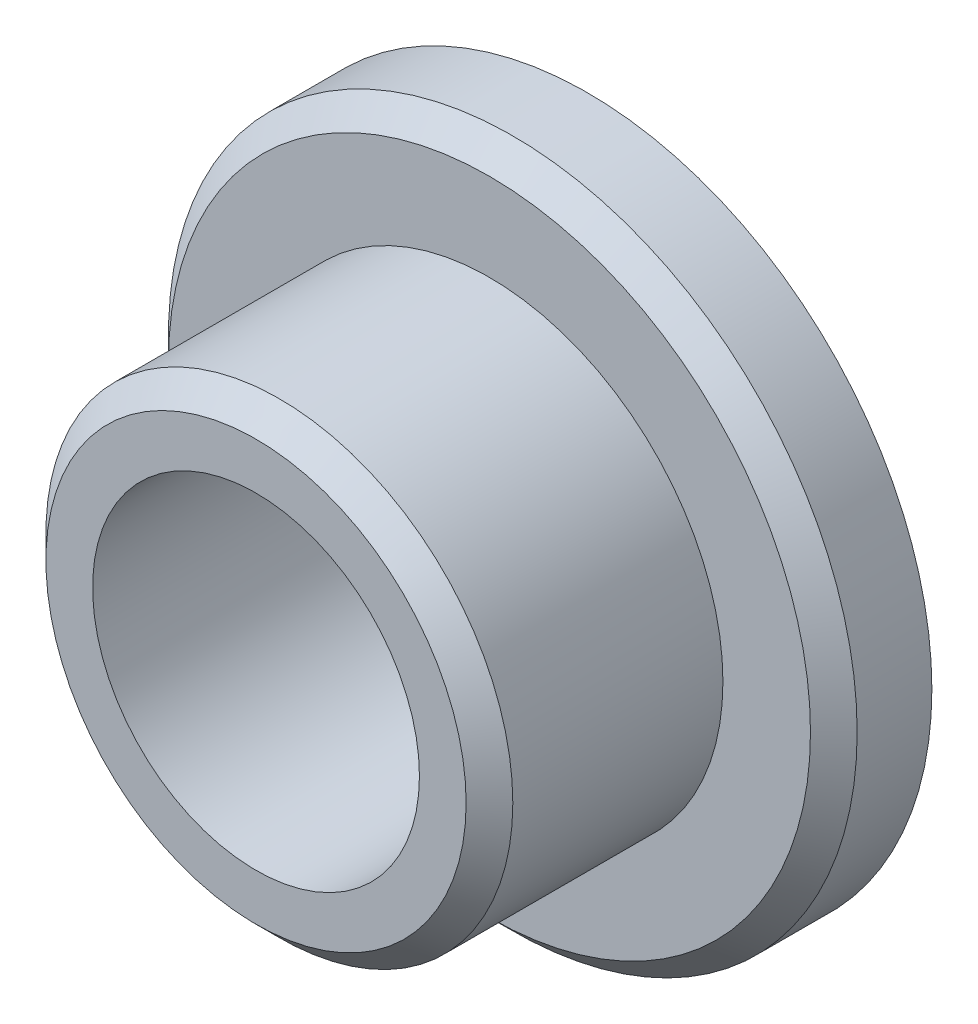
from build123d import *

# Parameters (mm, degrees)
SKETCH_1_R          = 14.75
EXTRUDE_1_DEPTH     = 4.2
SKETCH_2_R          = 10
EXTRUDE_2_DEPTH     = 10
SKETCH_3_R          = 7
CUT_EXTRUDE_1_DEPTH = 15.2
CHAMFER_1_SIZE      = 1


with BuildPart() as part:
    # 草图1 → 凸台-拉伸1 (new body)
    with BuildSketch(Plane.XY):
        Circle(SKETCH_1_R)
    extrude(amount=EXTRUDE_1_DEPTH)

    # 草图2 → 凸台-拉伸2 (add)
    with BuildSketch(Plane.XY.offset(4.2)):
        Circle(SKETCH_2_R)
    extrude(amount=EXTRUDE_2_DEPTH)

    # 草图3 → 切除-拉伸1 (cut, through all)
    with BuildSketch(Plane.XY.offset(14.2)):
        Circle(SKETCH_3_R)
    extrude(amount=-CUT_EXTRUDE_1_DEPTH, mode=Mode.SUBTRACT)

    # 倒角1
    chamfer_1_edges = [part.edges().sort_by_distance(p)[0] for p in [
        (-14.75, 0, 4.2),
        (-10, 0, 14.2),
    ]]
    chamfer(chamfer_1_edges, length=CHAMFER_1_SIZE)


solid = part.part
